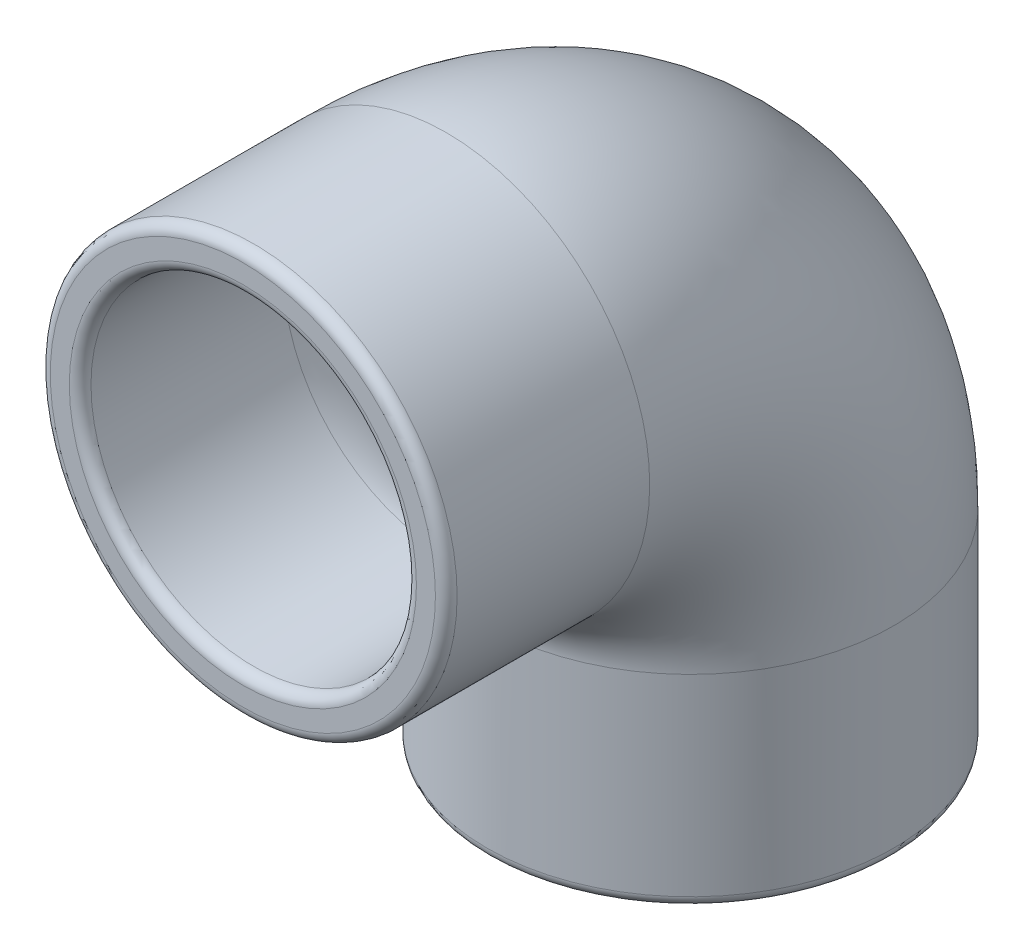
from build123d import *

# Parameters (mm, degrees)
SKETCH1_R   = 15
SKETCH1_R_2 = 12
FILLET4_R   = 0.8
FILLET5_R   = 0.8


with BuildPart() as part:
    # Sweep3: sweep along a path in Sketch2
    with BuildLine(Plane(origin=(0, 0, 0), x_dir=(0, 0, -1), z_dir=(1, 0, 0))) as sweep3_path:
        Line((0, 0), (15, 0))
        ThreePointArc((15, 0), (27.727922061, -5.272077939), (33, -18))
        Line((33, -18), (33, -33))
    # Sketch1 → Sweep3 (sweep)
    with BuildSketch(Plane.XY):
        Circle(SKETCH1_R)
        Circle(SKETCH1_R_2, mode=Mode.SUBTRACT)
    sweep(path=sweep3_path.line)

    # Fillet4
    fillet4_edges = [part.edges().sort_by_distance(p)[0] for p in [
        (-15, 0, 0),
        (-12, 0, 0),
    ]]
    fillet(fillet4_edges, radius=FILLET4_R)

    # Fillet5
    fillet5_edges = [part.edges().sort_by_distance(p)[0] for p in [
        (-12, -33, -33),
        (-15, -33, -33),
    ]]
    fillet(fillet5_edges, radius=FILLET5_R)


solid = part.part
